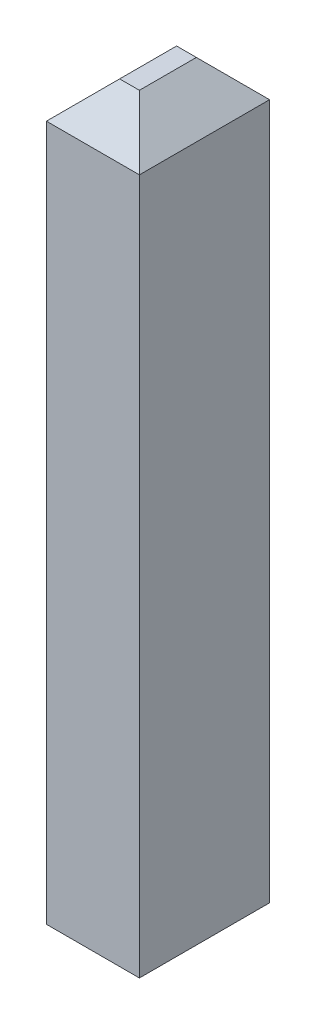
from build123d import *

# Parameters (mm, degrees)
SKETCH1_W           = 0.254
SKETCH1_H           = 0.3556
BOSS_EXTRUDE1_DEPTH = 2
CHAMFER1_SIZE       = 0.1
CHAMFER2_SIZE       = 0.1


with BuildPart() as part:
    # Sketch1 → Boss-Extrude1 (new body)
    with BuildSketch(Plane(origin=(0, 0, 0), x_dir=(1, 0, 0), z_dir=(0, 1, 0))):
        Rectangle(SKETCH1_W, SKETCH1_H)
    extrude(amount=BOSS_EXTRUDE1_DEPTH)

    # Chamfer1
    chamfer1_edges = [part.edges().sort_by_distance(p)[0] for p in [
        (0, 2, 0.1778),
        (0, 2, -0.1778),
    ]]
    chamfer(chamfer1_edges, length=CHAMFER1_SIZE)

    # Chamfer2
    chamfer2_edges = [part.edges().sort_by_distance(p)[0] for p in [
        (-0.127, 2, 0),
        (0.127, 2, 0),
    ]]
    chamfer(chamfer2_edges, length=CHAMFER2_SIZE)


solid = part.part
